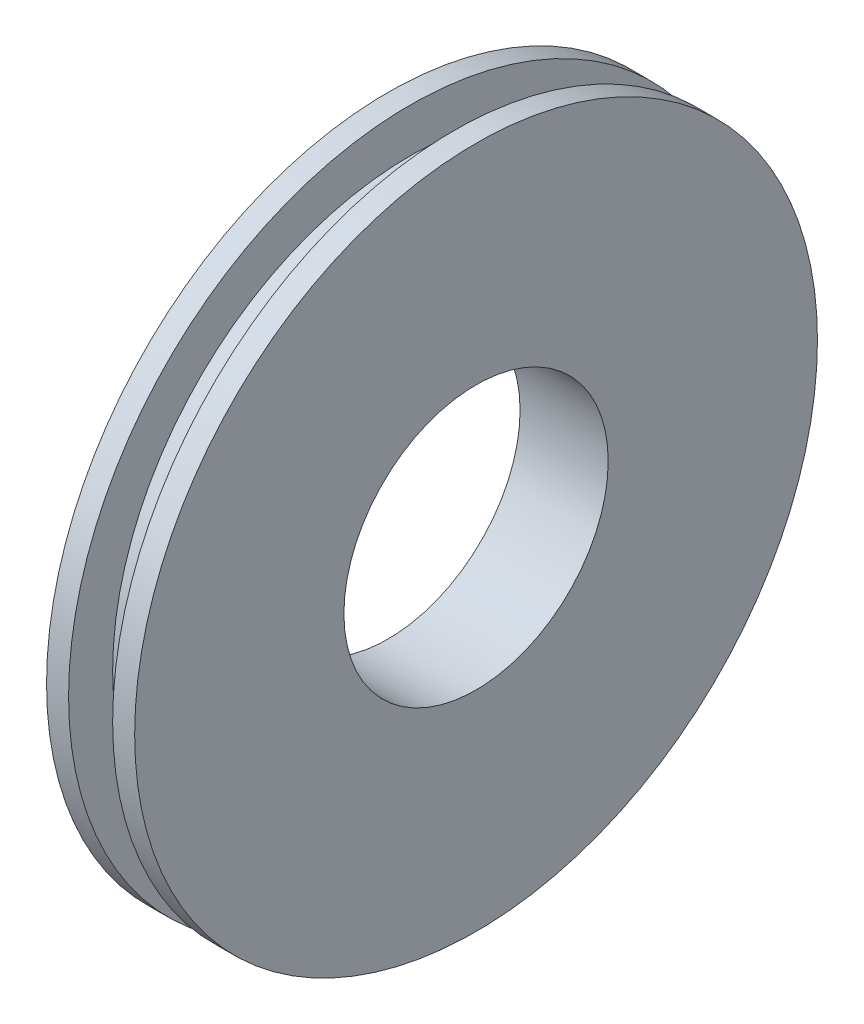
from build123d import *


with BuildPart() as part:
    # Skizze1 → Rotation1 (revolve)
    with BuildSketch(Plane.XY):
        Polygon((1, 3), (-1, 3), (-1, 7.75), (-0.5, 7.75), (-0.5, 6.75), (0.5, 6.75), (0.5, 7.75), (1, 7.75), align=None)
    revolve(axis=Axis((-47.576368058, 0, 0), (1, 0, 0)))


solid = part.part
